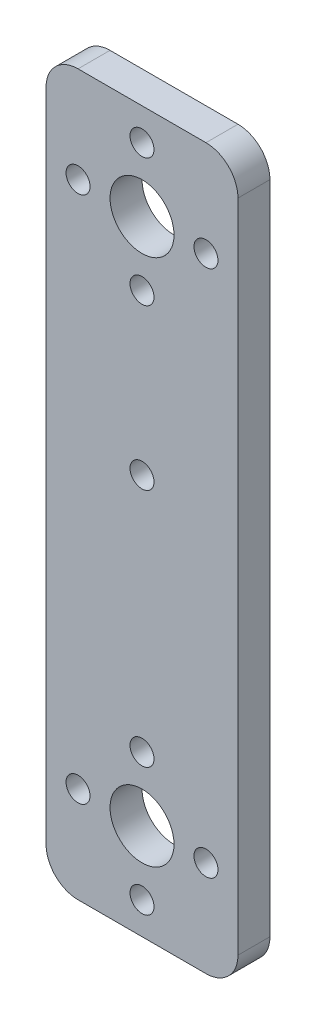
from build123d import *

# Parameters (mm, degrees)
SKETCH1_W           = 24
SKETCH1_H           = 90
BOSS_EXTRUDE1_DEPTH = 4
SKETCH2_R           = 4
SKETCH2_R_2         = 1.5
CUT_EXTRUDE1_DEPTH  = 4
FILLET1_R           = 4
SKETCH3_R           = 1.5
CUT_EXTRUDE2_DEPTH  = 4


with BuildPart() as part:
    # Sketch1 → Boss-Extrude1 (new body)
    with BuildSketch(Plane.XY):
        with Locations((-45.296675466, -10.049681021)):
            Rectangle(SKETCH1_W, SKETCH1_H)
    extrude(amount=BOSS_EXTRUDE1_DEPTH)

    # Sketch2 → Cut-Extrude1 (cut)
    with BuildSketch(Plane.XY.offset(4)):
        with Locations((-45.296675466, -43.049681021)):
            Circle(SKETCH2_R)
        with Locations((-37.296675466, -43.049681021)):
            Circle(SKETCH2_R_2)
        with Locations((-45.296675466, -51.049681021)):
            Circle(SKETCH2_R_2)
        with Locations((-53.296675466, -43.049681021)):
            Circle(SKETCH2_R_2)
        with Locations((-45.296675466, -35.049681021)):
            Circle(SKETCH2_R_2)
        with Locations((-45.296675466, 30.950318979)):
            Circle(SKETCH2_R_2)
        with Locations((-37.296675466, 22.950318979)):
            Circle(SKETCH2_R_2)
        with Locations((-45.296675466, 14.950318979)):
            Circle(SKETCH2_R_2)
        with Locations((-53.296675466, 22.950318979)):
            Circle(SKETCH2_R_2)
        with Locations((-45.296675466, 22.950318979)):
            Circle(SKETCH2_R)
    extrude(amount=-CUT_EXTRUDE1_DEPTH, mode=Mode.SUBTRACT)

    # Fillet1
    fillet1_edges = [part.edges().sort_by_distance(p)[0] for p in [
        (-57.296675466, 34.950318979, 2),
        (-57.296675466, -55.049681021, 2),
        (-33.296675466, -55.049681021, 2),
        (-33.296675466, 34.950318979, 2),
    ]]
    fillet(fillet1_edges, radius=FILLET1_R)

    # Sketch3 → Cut-Extrude2 (cut)
    with BuildSketch(Plane.XY.offset(4)):
        with Locations((-45.296675466, -5.049681021)):
            Circle(SKETCH3_R)
    extrude(amount=-CUT_EXTRUDE2_DEPTH, mode=Mode.SUBTRACT)


solid = part.part
